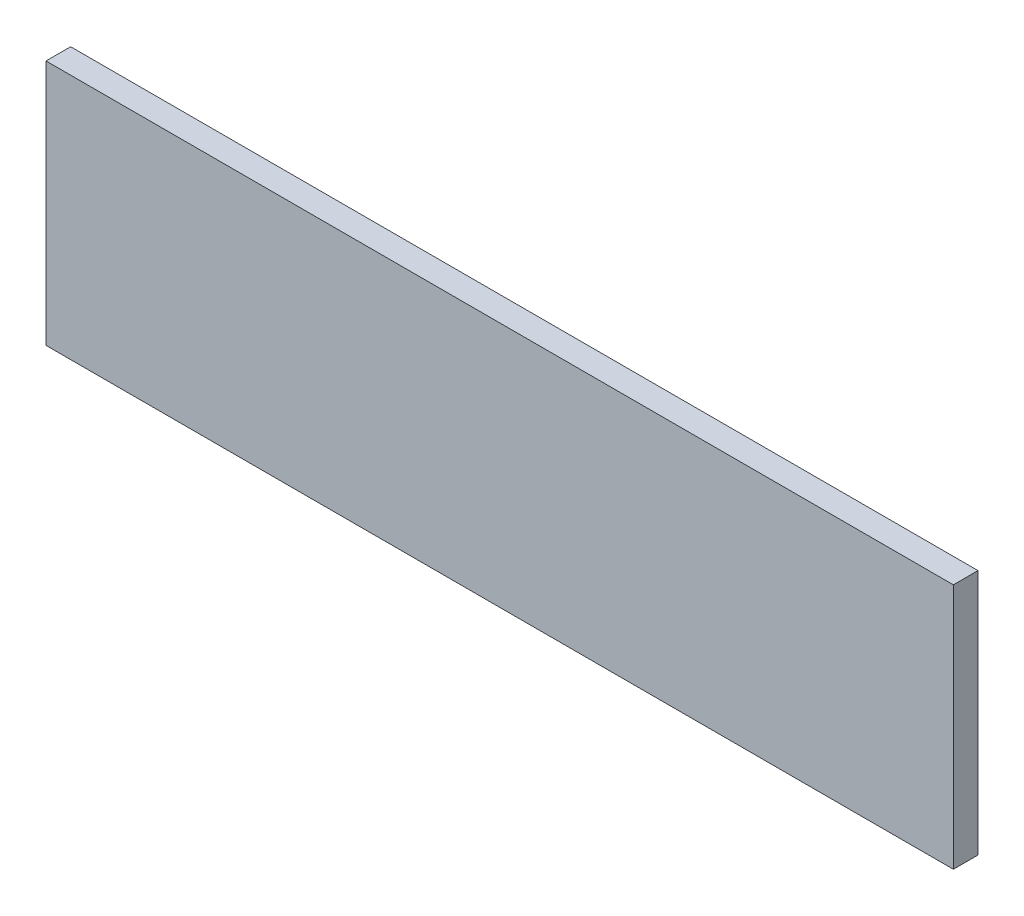
from build123d import *

# Parameters (mm, degrees)
CROQUIS1_W              = 3
CROQUIS1_H              = 30
SALIENTE_EXTRUIR1_DEPTH = 110.49


with BuildPart() as part:
    # Croquis1 → Saliente-Extruir1 (new body)
    with BuildSketch(Plane(origin=(0, 0, 0), x_dir=(0, 0, -1), z_dir=(1, 0, 0))):
        Rectangle(CROQUIS1_W, CROQUIS1_H)
    extrude(amount=SALIENTE_EXTRUIR1_DEPTH)


solid = part.part
